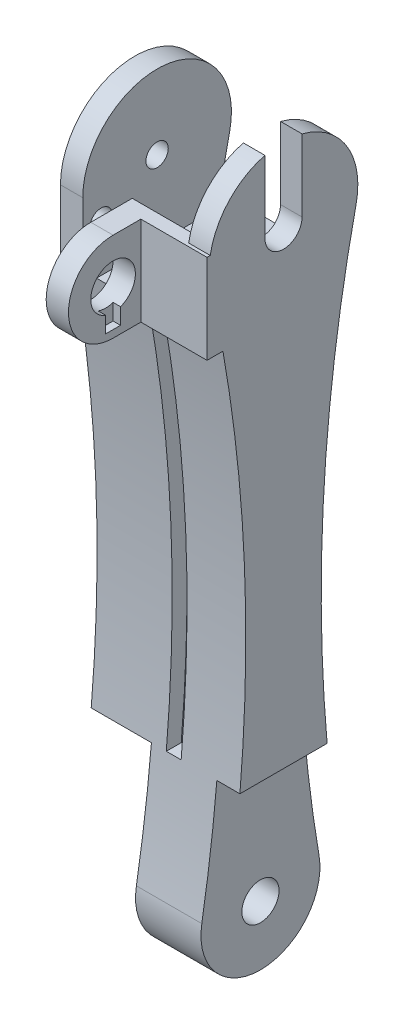
from build123d import *

# Parameters (mm, degrees)
SKETCH1_R                = 1.5
SKETCH1_R_2              = 2.5
BOSS_EXTRUDE1_DEPTH      = 20
SKETCH2_W                = 8.1
SKETCH2_H                = 25
SKETCH2_W_2              = 3.1
SKETCH2_W_3              = 5.1
SKETCH2_H_2              = 20
CUT_EXTRUDE1_DEPTH       = 20
CUT_EXTRUDE1_DEPTH_BACK  = 20
CUT_EXTRUDE2_DEPTH       = 9
BOSS_EXTRUDE2_DEPTH      = 11.9
SKETCH5_R                = 3
BOSS_EXTRUDE3_DEPTH      = 3
CUT_EXTRUDE6_DEPTH       = 1
SKETCH13_R               = 2.5
CUT_EXTRUDE7_DEPTH       = 4
CUT_EXTRUDE5_START       = 5
CUT_EXTRUDE5_DEPTH       = 2
CUT_EXTRUDE8_REACH       = 22
SKETCH14_R               = 1.5
BOSS_EXTRUDE4_DEPTH      = 3
CUT_EXTRUDE9_DEPTH       = 3
SKETCH17_W               = 9
SKETCH17_H               = 3.569322199
CUT_EXTRUDE11_DEPTH      = 3
SKETCH18_W               = 5.770974844
SKETCH18_H               = 0.772936936
BOSS_EXTRUDE5_DEPTH      = 8.9
BOSS_EXTRUDE5_DEPTH_BACK = 1
SKETCH19_W               = 5.1
SKETCH19_H               = 16.397725614
CUT_EXTRUDE12_DEPTH      = 0.301495
SKETCH20_W               = 5
SKETCH20_H               = 12.419235667
CUT_EXTRUDE13_DEPTH      = 10


with BuildPart() as part:
    # Sketch1 → Boss-Extrude1 (new body)
    with BuildSketch(Plane(origin=(0, 0, 0), x_dir=(0, 0, -1), z_dir=(1, 0, 0))):
        with BuildLine():
            ThreePointArc((9.765353557, 20.116545894), (0, 32.270117322), (-9.765353557, 20.116545894))
            ThreePointArc((-9.765353557, 20.116545894), (-5.132645827, -18.047253777), (-7.88740095, -56.392382678))
            ThreePointArc((-7.88740095, -56.392382678), (0, -65.729882678), (7.88740095, -56.392382678))
            ThreePointArc((7.88740095, -56.392382678), (5.132645827, -18.047253777), (9.765353557, 20.116545894))
        make_face()
        with Locations((0, 22.270117322)):
            Circle(SKETCH1_R, mode=Mode.SUBTRACT)
        with Locations((0, -57.729882678)):
            Circle(SKETCH1_R_2, mode=Mode.SUBTRACT)
    extrude(amount=BOSS_EXTRUDE1_DEPTH)

    # Sketch2 → Cut-Extrude1 (cut, two sides)
    with BuildSketch(Plane.XY) as cut_extrude1_sk:
        with Locations((4.05, -53.229882678)):
            Rectangle(SKETCH2_W, SKETCH2_H)
        with Locations((18.45, -53.229882678)):
            Rectangle(SKETCH2_W_2, SKETCH2_H)
        with Locations((5.55, 22.270117322)):
            Rectangle(SKETCH2_W_3, SKETCH2_H_2)
    extrude(amount=CUT_EXTRUDE1_DEPTH, mode=Mode.SUBTRACT)
    extrude(cut_extrude1_sk.sketch, amount=-CUT_EXTRUDE1_DEPTH_BACK, mode=Mode.SUBTRACT)

    # Sketch3 → Cut-Extrude2 (cut)
    with BuildSketch(Plane.ZY.offset(-8.1)):
        with BuildLine():
            Line((8.5, 22.270117322), (8.5, 40.909533312))
            Line((8.5, 40.909533312), (-17.52872033, 40.909533312))
            Line((-17.52872033, 40.909533312), (-17.52872033, 13.770117322))
            Line((-17.52872033, 13.770117322), (0, 13.770117322))
            ThreePointArc((0, 13.770117322), (6.01040764, 16.259709682), (8.5, 22.270117322))
        make_face()
    extrude(amount=-CUT_EXTRUDE2_DEPTH, mode=Mode.SUBTRACT)

    # Sketch4 → Boss-Extrude2 (add, through all)
    with BuildSketch(Plane.ZY.offset(-8.1)):
        Polygon((8.5, 27.537944199), (8.283796844, 12.741558936), (10.283796844, 12.741558936), (10.283796844, 27.537944199), align=None)
    extrude(amount=-BOSS_EXTRUDE2_DEPTH)

    # Sketch5 → Boss-Extrude3 (add)
    with BuildSketch(Plane.ZY.offset(-8.1)):
        with BuildLine():
            Line((8.145156861, 11.968622), (8.447845456, 23.968622))
            Line((8.447845456, 23.968622), (9.854698466, 23.968622))
            Line((9.854698466, 23.968622), (14.022421388, 23.968622))
            ThreePointArc((14.022421388, 23.968622), (20.022421388, 17.968622), (14.022421388, 11.968622))
            Line((14.022421388, 11.968622), (8.145156861, 11.968622))
        make_face()
        with Locations((14.022421388, 17.968622)):
            Circle(SKETCH5_R, mode=Mode.SUBTRACT)
    extrude(amount=-BOSS_EXTRUDE3_DEPTH)

    # Sketch12 → Cut-Extrude6 (cut)
    with BuildSketch(Plane(origin=(11.1, 0, 0), x_dir=(0, 0, -1), z_dir=(1, 0, 0))):
        Polygon((-15.022421388, 13.968622), (-15.022421388, 12.968622), (-13.022421388, 12.968622), (-13.022421388, 13.968622), (-13.022421388, 15.140194875), (-14.022421388, 15.140194875), (-15.022421388, 15.140194875), align=None)
    extrude(amount=-CUT_EXTRUDE6_DEPTH, mode=Mode.SUBTRACT)

    # Sketch13 → Cut-Extrude7 (cut)
    with BuildSketch(Plane.ZY.offset(-17.1)):
        with Locations((0, 22.270117322)):
            Circle(SKETCH13_R)
    extrude(amount=-CUT_EXTRUDE7_DEPTH, mode=Mode.SUBTRACT)

    # Sketch10 → Cut-Extrude5 (cut)
    with BuildSketch(Plane.ZY.offset(-17.1).offset(CUT_EXTRUDE5_START)):
        with BuildLine():
            Line((8.283796844, 12.741558936), (6.251490054, 12.741558936))
            ThreePointArc((6.251490054, 12.741558936), (3.274825885, -13.914467314), (3.856000489, -40.729882678))
            Line((3.856000489, -40.729882678), (5.863867222, -40.729882678))
            Line((5.863867222, -40.729882678), (7.833024243, -40.729882678))
            Line((7.833024243, -40.729882678), (8.283796844, 12.741558936))
        make_face()
    extrude(amount=CUT_EXTRUDE5_DEPTH, mode=Mode.SUBTRACT)

    # Sketch14 → Cut-Extrude8 (cut, up to next)
    with BuildSketch(Plane.ZY, mode=Mode.PRIVATE) as cut_extrude8_sk1:
        with Locations((7.532575614, 18.331804915)):
            Circle(SKETCH14_R)
    cut_extrude8_tool1 = extrude(cut_extrude8_sk1.sketch, amount=-CUT_EXTRUDE8_REACH, mode=Mode.PRIVATE) & part.part
    add(cut_extrude8_tool1.solids().sort_by_distance((0, 18.331805, 7.532576))[0], mode=Mode.SUBTRACT)

    # Sketch15 → Boss-Extrude4 (add)
    with BuildSketch(Plane.ZY):
        Polygon((10, 22.270117322), (10, 11.968622), (8.145156861, 11.968622), (7.595672539, 11.968622), align=None)
    extrude(amount=-BOSS_EXTRUDE4_DEPTH)

    # Sketch16 → Cut-Extrude9 (cut)
    with BuildSketch(Plane(origin=(20, 0, 0), x_dir=(0, 0, -1), z_dir=(1, 0, 0))):
        with BuildLine():
            Line((-10.283796844, 23.968622), (-9.854698466, 23.968622))
            ThreePointArc((-9.854698466, 23.968622), (-9.349264901, 25.818531871), (-8.5, 27.537944199))
            Line((-8.5, 27.537944199), (-10.283796844, 27.537944199))
            Line((-10.283796844, 27.537944199), (-10.283796844, 23.968622))
        make_face()
    extrude(amount=-CUT_EXTRUDE9_DEPTH, mode=Mode.SUBTRACT)

    # Sketch17 → Cut-Extrude11 (cut)
    with BuildSketch(Plane.XY.offset(10.283796844)):
        with Locations((12.6, 25.7532831)):
            Rectangle(SKETCH17_W, SKETCH17_H)
    extrude(amount=-CUT_EXTRUDE11_DEPTH, mode=Mode.SUBTRACT)

    # Sketch18 → Boss-Extrude5 (add, two sides)
    with BuildSketch(Plane(origin=(11.1, 0, 0), x_dir=(0, 0, -1), z_dir=(1, 0, 0))) as boss_extrude5_sk:
        with Locations((-7.398309422, 12.355090468)):
            Rectangle(SKETCH18_W, SKETCH18_H)
    extrude(amount=BOSS_EXTRUDE5_DEPTH)
    extrude(boss_extrude5_sk.sketch, amount=-BOSS_EXTRUDE5_DEPTH_BACK)

    # Sketch19 → Cut-Extrude12 (cut)
    with BuildSketch(Plane(origin=(0, 12.270117322, 0), x_dir=(1, 0, 0), z_dir=(0, 1, 0))):
        with Locations((5.55, 0)):
            Rectangle(SKETCH19_W, SKETCH19_H)
    extrude(amount=-CUT_EXTRUDE12_DEPTH, mode=Mode.SUBTRACT)

    # Sketch20 → Cut-Extrude13 (cut)
    with BuildSketch(Plane.ZY.offset(-17.1)):
        with Locations((0, 28.479735156)):
            Rectangle(SKETCH20_W, SKETCH20_H)
    extrude(amount=-CUT_EXTRUDE13_DEPTH, mode=Mode.SUBTRACT)


solid = part.part
